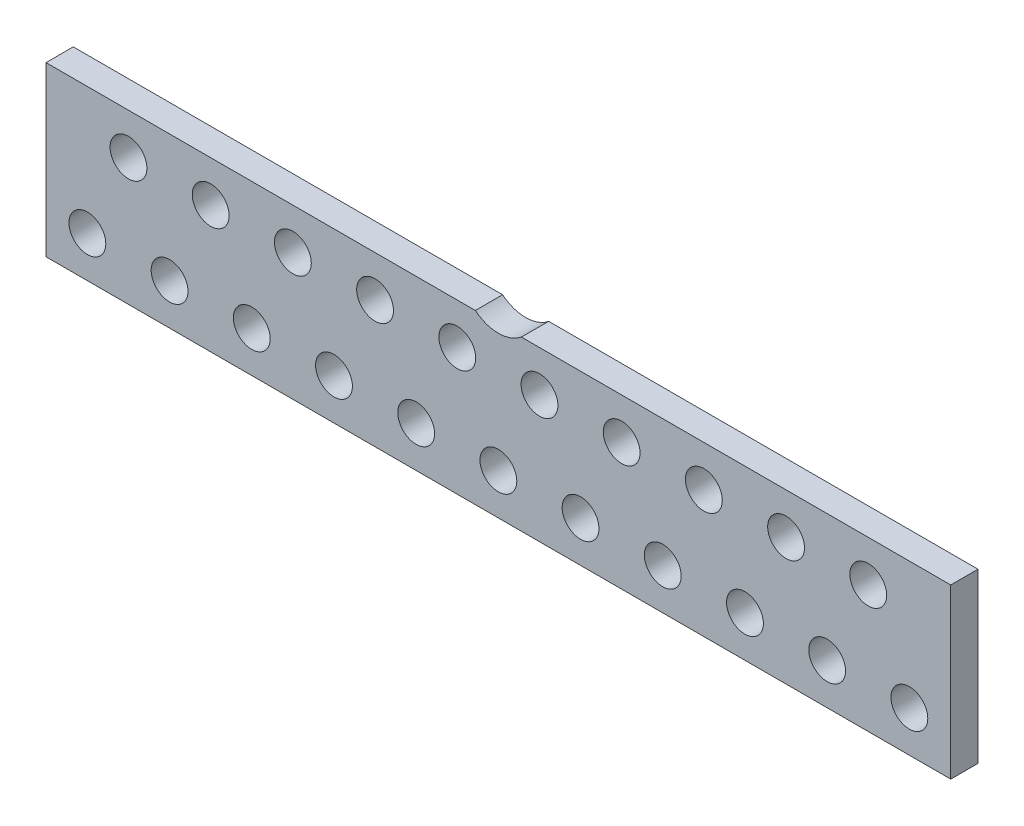
from build123d import *

# Parameters (mm, degrees)
BOSS_EXTRUDE1_DEPTH = 1.194
SKETCH2_R           = 0.8065
CUT_EXTRUDE1_DEPTH  = 2.194


with BuildPart() as part:
    # Sketch1 → Boss-Extrude1 (new body)
    with BuildSketch(Plane.XY.offset(2.26)):
        with BuildLine():
            Line((-1.008396957, 3.683), (-19.812, 3.683))
            Line((-19.812, 3.683), (-19.812, -3.683))
            Line((-19.812, -3.683), (19.812, -3.683))
            Line((19.812, -3.683), (19.812, 3.683))
            Line((19.812, 3.683), (1.008396957, 3.683))
            ThreePointArc((1.008396957, 3.683), (0, 3.322929517), (-1.008396957, 3.683))
        make_face()
    extrude(amount=-BOSS_EXTRUDE1_DEPTH)

    # Sketch2 → Cut-Extrude1 (cut, through all)
    with BuildSketch(Plane.XY.offset(2.26)):
        with Locations((-18, -1.885)):
            Circle(SKETCH2_R)
        with Locations((-16.2, 1.885)):
            Circle(SKETCH2_R)
        with Locations((-14.4, -1.885)):
            Circle(SKETCH2_R)
        with Locations((-10.8, -1.885)):
            Circle(SKETCH2_R)
        with Locations((-7.2, -1.885)):
            Circle(SKETCH2_R)
        with Locations((-3.6, -1.885)):
            Circle(SKETCH2_R)
        with Locations((0, -1.885)):
            Circle(SKETCH2_R)
        with Locations((3.6, -1.885)):
            Circle(SKETCH2_R)
        with Locations((7.2, -1.885)):
            Circle(SKETCH2_R)
        with Locations((10.8, -1.885)):
            Circle(SKETCH2_R)
        with Locations((14.4, -1.885)):
            Circle(SKETCH2_R)
        with Locations((18, -1.885)):
            Circle(SKETCH2_R)
        with Locations((-12.6, 1.885)):
            Circle(SKETCH2_R)
        with Locations((-9, 1.885)):
            Circle(SKETCH2_R)
        with Locations((-5.4, 1.885)):
            Circle(SKETCH2_R)
        with Locations((-1.8, 1.885)):
            Circle(SKETCH2_R)
        with Locations((1.8, 1.885)):
            Circle(SKETCH2_R)
        with Locations((5.4, 1.885)):
            Circle(SKETCH2_R)
        with Locations((9, 1.885)):
            Circle(SKETCH2_R)
        with Locations((12.6, 1.885)):
            Circle(SKETCH2_R)
        with Locations((16.2, 1.885)):
            Circle(SKETCH2_R)
    extrude(amount=-CUT_EXTRUDE1_DEPTH, mode=Mode.SUBTRACT)


solid = part.part
